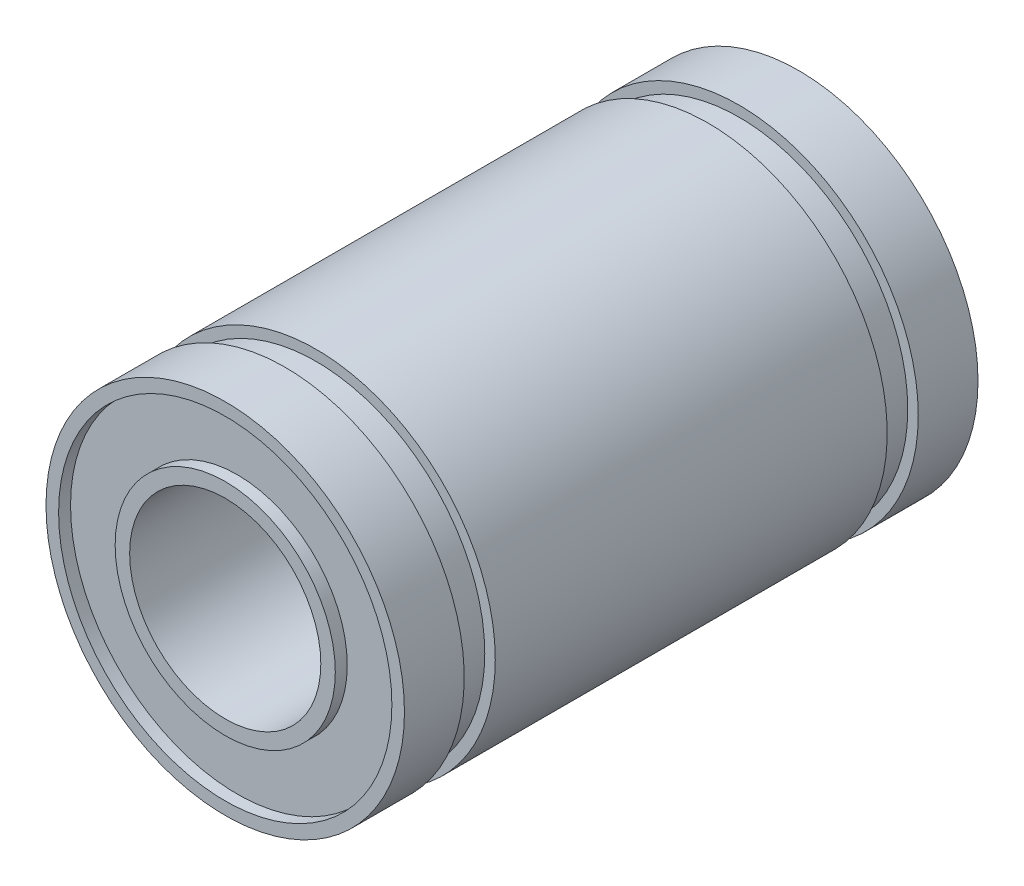
from build123d import *

# Parameters (mm, degrees)
SKETCH1_R           = 7.5
SKETCH1_R_2         = 4
BOSS_EXTRUDE1_DEPTH = 12
SKETCH2_W           = 0.934125578
SKETCH2_H           = 1.3
SKETCH3_R           = 6.972941291
SKETCH3_R_2         = 4.606383091
CUT_EXTRUDE1_DEPTH  = 0.5


with BuildPart() as part:
    # Sketch1 → Boss-Extrude1 (new body, symmetric)
    with BuildSketch(Plane.XY):
        Circle(SKETCH1_R)
        Circle(SKETCH1_R_2, mode=Mode.SUBTRACT)
    extrude(amount=BOSS_EXTRUDE1_DEPTH, both=True)

    # Sketch2 → Cut-Revolve1 (revolve, cut)
    with BuildSketch(Plane(origin=(0, 0, 0), x_dir=(1, 0, 0), z_dir=(0, 1, 0))):
        with Locations((7.527516863, -8.85)):
            Rectangle(SKETCH2_W, SKETCH2_H)
        with Locations((7.527516863, 8.85)):
            Rectangle(SKETCH2_W, SKETCH2_H)
    revolve(axis=Axis((0, 0, -13.646970123), (0, 0, 1)), mode=Mode.SUBTRACT)

    # Sketch3 → Cut-Extrude1 (cut)
    with BuildSketch(Plane(origin=(0, 0, -12), x_dir=(-1, 0, 0), z_dir=(0, 0, -1))):
        Circle(SKETCH3_R)
        Circle(SKETCH3_R_2, mode=Mode.SUBTRACT)
    cut_extrude1 = extrude(amount=-CUT_EXTRUDE1_DEPTH, mode=Mode.SUBTRACT)

    # Mirror1: Cut-Extrude1 across plane
    add(cut_extrude1.mirror(Plane.XY), mode=Mode.SUBTRACT)


solid = part.part
